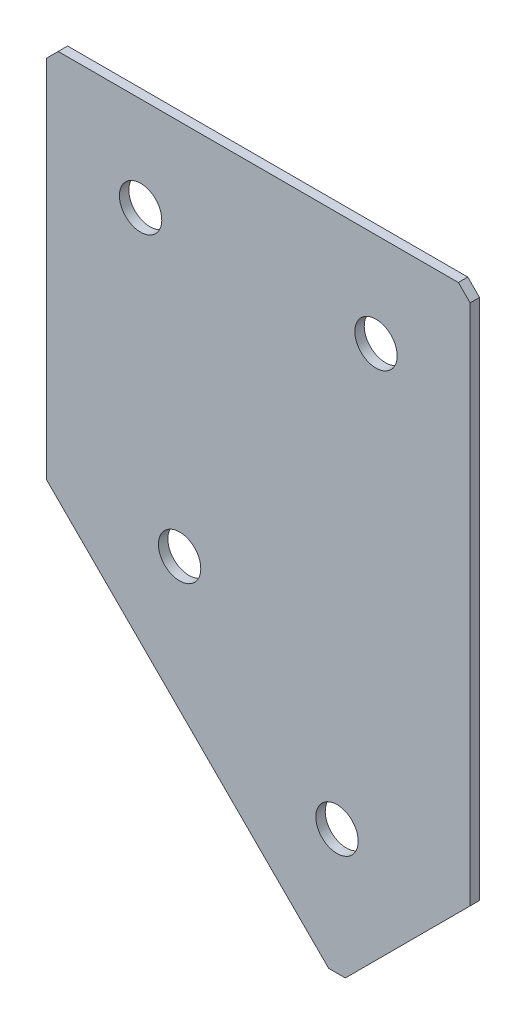
from build123d import *

# Parameters (mm, degrees)
EXTRUDE_1_DEPTH   = 2
HOLE_WIZARD_M81_D = 9
CHAMFER_1_SIZE    = 2.5


with BuildPart() as part:
    # Эскиз3 → Бобышка-Вытянуть1 (new body)
    with BuildSketch(Plane(origin=(0, 0, 0), x_dir=(1, 0, 0), z_dir=(0, 0, -1))):
        Polygon((0, 0), (90, 0), (90, 113.431457505), (61.715728753, 141.715728753), (0, 80), align=None)
    extrude(amount=EXTRUDE_1_DEPTH)

    # Отверстие с зазором M81 (through all)
    with Locations(Plane(origin=(0, 0, -2), x_dir=(1, 0, 0), z_dir=(0, 0, -1))):
        with Locations((20, 20), (70, 20), (28.284271247, 80), (61.715728753, 113.431457505)):
            Hole(HOLE_WIZARD_M81_D / 2)

    # Фаска1
    chamfer_1_edges = [part.edges().sort_by_distance(p)[0] for p in [
        (61.715728753, -141.715728753, -1),
        (90, 0, -1),
        (0, 0, -1),
    ]]
    chamfer(chamfer_1_edges, length=CHAMFER_1_SIZE)


solid = part.part
